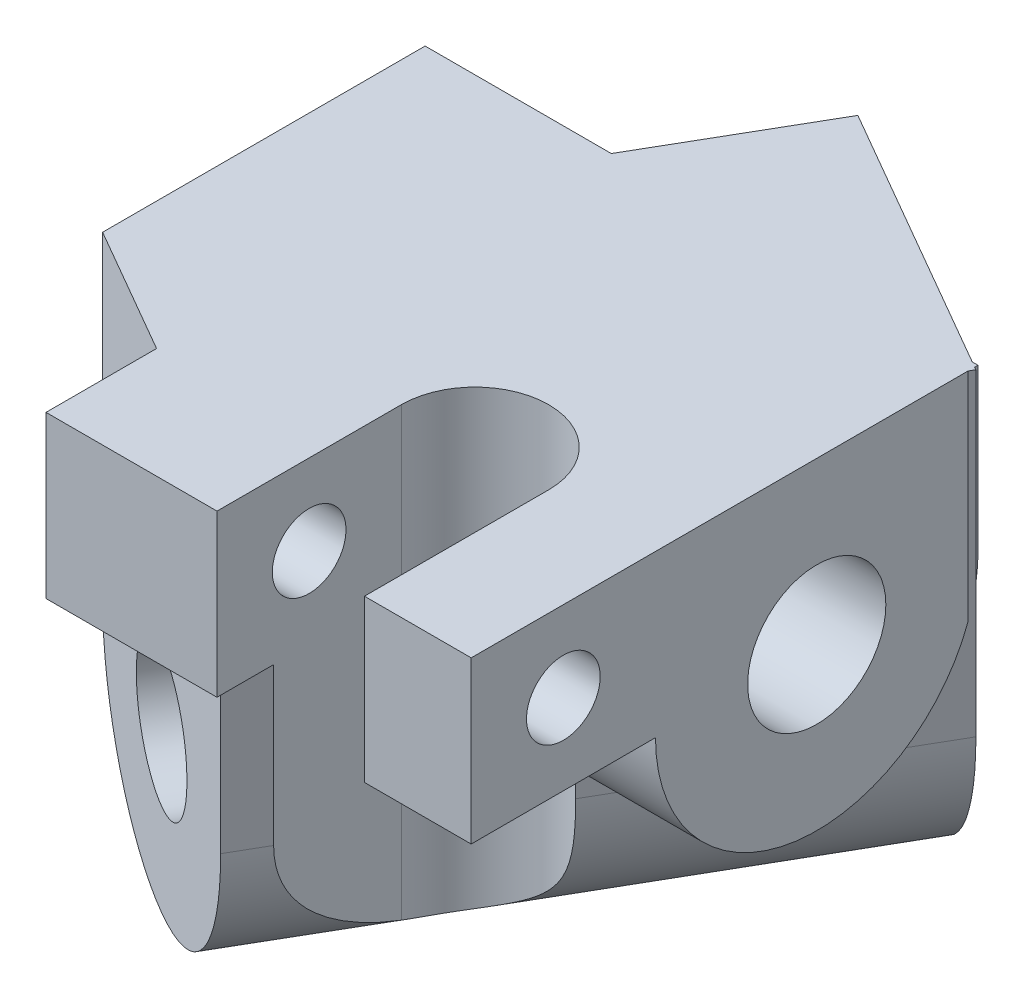
from build123d import *

# Parameters (mm, degrees)
SKETCH1_R           = 3.75
BOSS_EXTRUDE1_DEPTH = 30
SKETCH2_R           = 3.75
BOSS_EXTRUDE2_DEPTH = 30
CUT_EXTRUDE1_DEPTH  = 27.0000001
SKETCH4_W           = 5.792740578
SKETCH4_H           = 10
BOSS_EXTRUDE3_DEPTH = 8.75
BOSS_EXTRUDE4_DEPTH = 8.75
SKETCH5_R           = 2
CUT_EXTRUDE2_DEPTH  = 31.0000001
SKETCH7_R           = 3.75
CUT_EXTRUDE3_DEPTH  = 31.155444666
SKETCH8_R           = 3.75
CUT_EXTRUDE4_DEPTH  = 38.57772242


with BuildPart() as part:
    # Sketch1 → Boss-Extrude1 (new body)
    with BuildSketch(Plane(origin=(0, 0, 0), x_dir=(0, 0, -1), z_dir=(1, 0, 0))):
        with BuildLine():
            Line((-8.75, 0), (8.75, 0))
            Line((8.75, 0), (8.75, 8.75))
            ThreePointArc((8.75, 8.75), (0, 17.5), (-8.75, 8.75))
            Line((-8.75, 8.75), (-8.75, 0))
        make_face()
        with Locations((0, 8.75)):
            Circle(SKETCH1_R, mode=Mode.SUBTRACT)
    extrude(amount=BOSS_EXTRUDE1_DEPTH)

    # Sketch2 → Boss-Extrude2 (add)
    with BuildSketch(Plane(origin=(-3.788861142, 0, 6.5625), x_dir=(-0.866025404, 0, -0.5), z_dir=(0.5, 0, -0.866025404))):
        with BuildLine():
            Line((-4.375, 0), (-4.375, 17.25))
            ThreePointArc((-4.375, 17.25), (-13.125, 26), (-21.875, 17.25))
            Line((-21.875, 17.25), (-21.875, 0))
            Line((-21.875, 0), (-4.375, 0))
        make_face()
        with Locations((-13.125, 17.25)):
            Circle(SKETCH2_R, mode=Mode.SUBTRACT)
    extrude(amount=BOSS_EXTRUDE2_DEPTH)

    # Sketch3 → Cut-Extrude1 (cut, through all)
    with BuildSketch(Plane.XZ):
        with BuildLine():
            Line((24.207259422, 8.75), (24.207259422, 15.67820323))
            Line((24.207259422, 15.67820323), (16.207259422, 15.67820323))
            Line((16.207259422, 15.67820323), (16.207259422, 8.75))
            ThreePointArc((16.207259422, 8.75), (20.207259422, 4.75), (24.207259422, 8.75))
        make_face()
    extrude(amount=-CUT_EXTRUDE1_DEPTH, mode=Mode.SUBTRACT)

    # Sketch4 → Boss-Extrude3 (add)
    with BuildSketch(Plane.XZ):
        with Locations((27.103629711, 13.75)):
            Rectangle(SKETCH4_W, SKETCH4_H)
    extrude(amount=-BOSS_EXTRUDE3_DEPTH)

    # Sketch6 → Boss-Extrude4 (add)
    with BuildSketch(Plane.XZ):
        Polygon((16.207259422, 15.67820323), (16.207259422, 18.75), (6.92820323, 18.75), (6.92820323, 12.75), align=None)
    extrude(amount=-BOSS_EXTRUDE4_DEPTH)

    # Sketch5 → Cut-Extrude2 (cut, through all)
    with BuildSketch(Plane(origin=(30, 0, 0), x_dir=(0, 0, -1), z_dir=(1, 0, 0))):
        with Locations(Location((-13.75, 4.375, 0), (0, 0, 60))):  # turned: the seam where the file's is
            Circle(SKETCH5_R)
    extrude(amount=-CUT_EXTRUDE2_DEPTH, mode=Mode.SUBTRACT)

    # Sketch7 → Cut-Extrude3 (cut, through all)
    with BuildSketch(Plane.ZY):
        with Locations(Location((0, 8.75, 0), (0, 0, 180))):  # turned: the seam where the file's is
            Circle(SKETCH7_R)
    extrude(amount=-CUT_EXTRUDE3_DEPTH, mode=Mode.SUBTRACT)

    # Sketch8 → Cut-Extrude4 (cut, through all)
    with BuildSketch(Plane(origin=(-3.788861142, 0, 6.5625), x_dir=(0.866025404, 0, 0.5), z_dir=(-0.5, 0, 0.866025404))):
        with Locations(Location((13.125, 17.25, 0), (0, 0, 180))):  # turned: the seam where the file's is
            Circle(SKETCH8_R)
    extrude(amount=-CUT_EXTRUDE4_DEPTH, mode=Mode.SUBTRACT)


with BuildPart() as body_2:
    # Mirror1: mirrored copy
    add(part.part.mirror(Plane(origin=(30, 0, 8.75), x_dir=(0, 0, 1), z_dir=(0, 1, 0))))


solid = body_2.part
